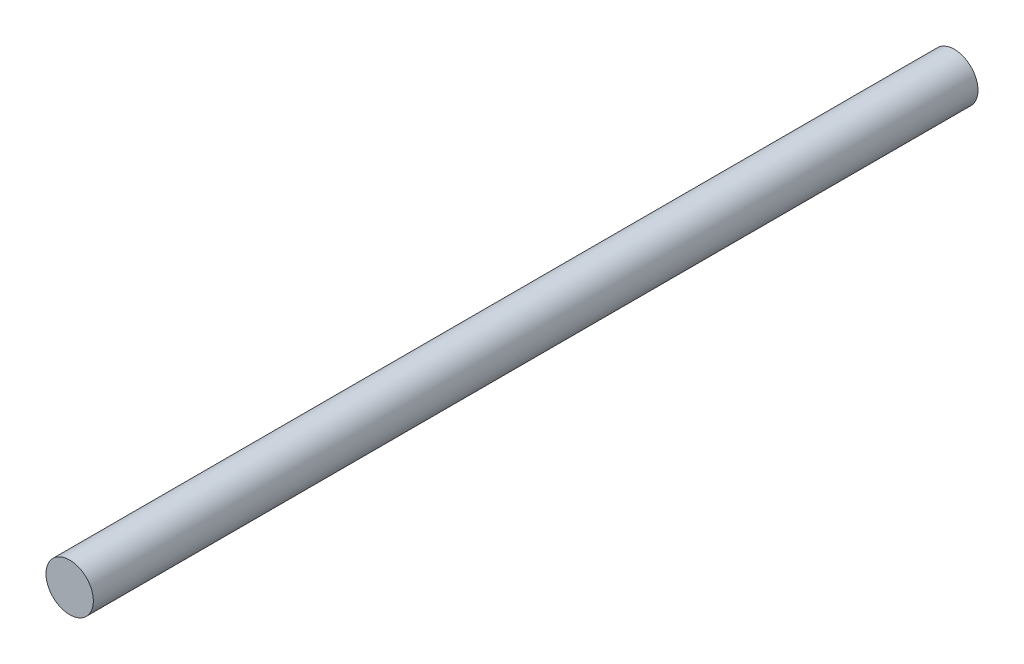
from build123d import *

# Parameters (mm, degrees)
SKETCH1_R           = 9.525
BOSS_EXTRUDE1_DEPTH = 355.6


with BuildPart() as part:
    # Sketch1 → Boss-Extrude1 (new body)
    with BuildSketch(Plane.XY):
        Circle(SKETCH1_R)
    extrude(amount=BOSS_EXTRUDE1_DEPTH)


solid = part.part
